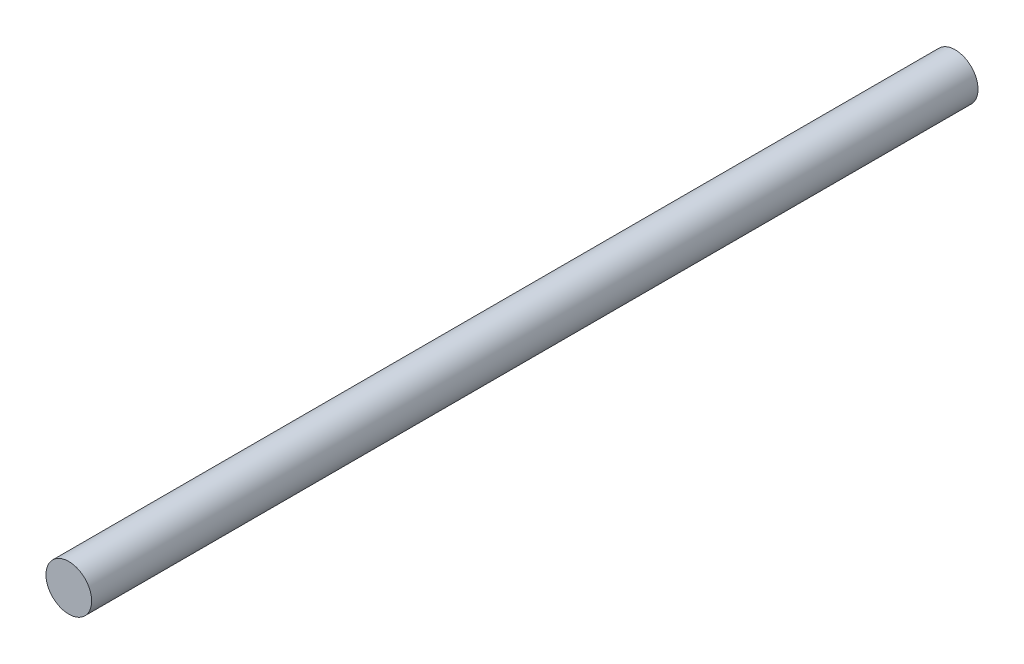
from build123d import *

# Parameters (mm, degrees)
SKETCH1_R           = 2.5
BOSS_EXTRUDE1_DEPTH = 97


with BuildPart() as part:
    # Sketch1 → Boss-Extrude1 (new body)
    with BuildSketch(Plane.XY):
        Circle(SKETCH1_R)
    extrude(amount=BOSS_EXTRUDE1_DEPTH)


solid = part.part
